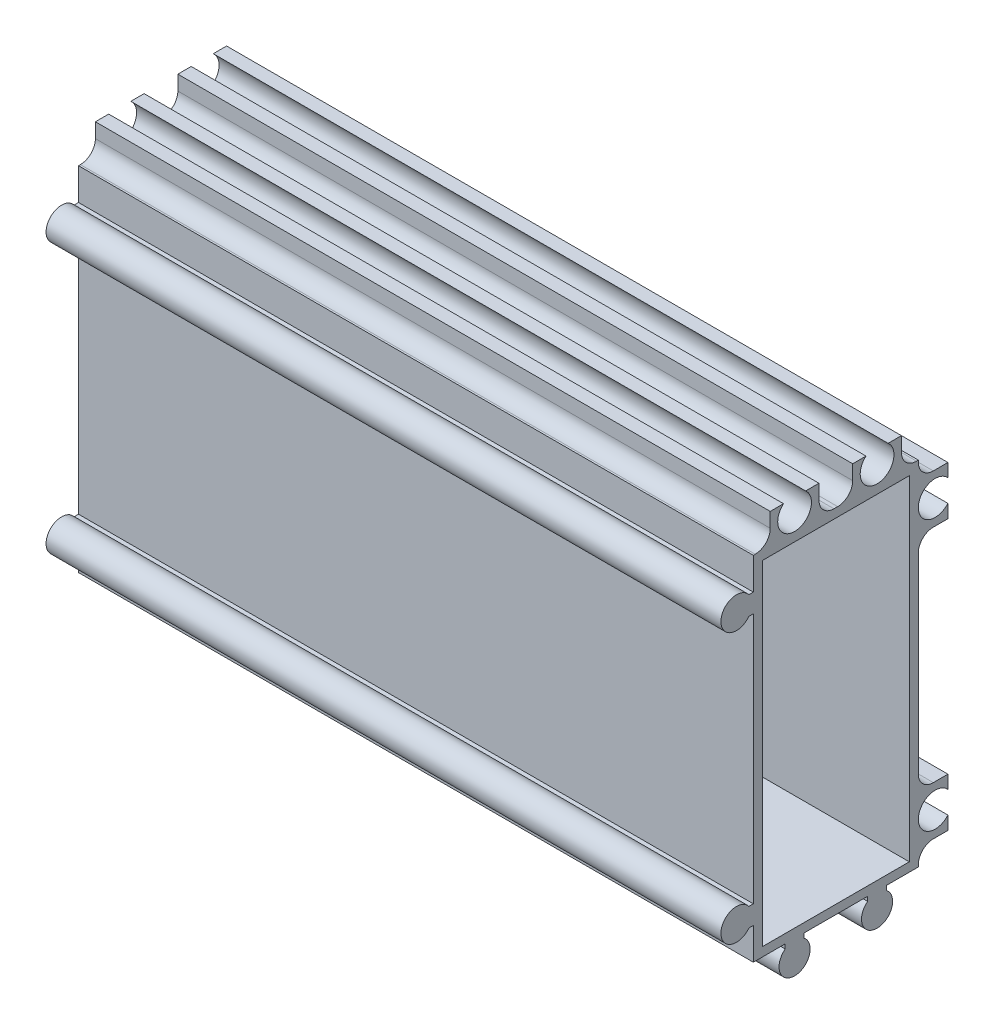
from build123d import *

# Parameters (mm, degrees)
EXTRUDE_1_DEPTH             = 90
SKETCH_2_W                  = 90
SKETCH_2_H                  = 17.75
EXTRUDE_2_DEPTH             = 8.2
SKETCH_3_W                  = 90
SKETCH_3_H                  = 50.95
EXTRUDE_3_DEPTH             = 8.2
SKETCH_4_W                  = 3.95
SKETCH_4_H                  = 29.5
CUT_EXTRUDE_1_DEPTH         = 91
SKETCH_5_W                  = 3.95
SKETCH_5_H                  = 6.2
CUT_EXTRUDE_2_DEPTH         = 91
SKETCH_6_W                  = 2.25
SKETCH_6_H                  = 3.95
CUT_EXTRUDE_3_DEPTH         = 91
SKETCH_7_W                  = 4.5
SKETCH_7_H                  = 3.95
CUT_EXTRUDE_4_DEPTH         = 91
SKETCH_8_W                  = 2.25
SKETCH_8_H                  = 3.95
CUT_EXTRUDE_5_DEPTH         = 91
SKETCH_9_W                  = 3.95
SKETCH_9_H                  = 2.25
CUT_EXTRUDE_6_DEPTH         = 91
SKETCH_10_W                 = 19.6
SKETCH_10_H                 = 44.6
CUT_EXTRUDE_7_DEPTH         = 86.2
HOLE_WIZARD_2_5_2_5_1_D     = 2.5
HOLE_WIZARD_2_5_2_5_1_DEPTH = 90
HOLE_WIZARD_4_5_4_5_1_D     = 4.5
HOLE_WIZARD_4_5_4_5_1_DEPTH = 90
FILLET_1_R                  = 2
FILLET_2_R                  = 2
SKETCH_17_R                 = 1.25
EXTRUDE_4_DEPTH             = 90


with BuildPart() as part:
    # Эскиз1 → Бобышка-Вытянуть1 (new body)
    with BuildSketch(Plane(origin=(90, 0, 0), x_dir=(0, 0, -1), z_dir=(1, 0, 0))):
        with BuildLine():
            Line((6.75, -24.093761792), (6.75, 19.25))
            Line((6.75, 19.25), (-11.593761792, 19.25))
            ThreePointArc((-11.593761792, 19.25), (-15.325, 18), (-11.593761792, 16.75))
            Line((-11.593761792, 16.75), (-11, 16.75))
            Line((-11, 16.75), (-11, -16.75))
            Line((-11, -16.75), (-11.593761792, -16.75))
            ThreePointArc((-11.593761792, -16.75), (-15.325, -18), (-11.593761792, -19.25))
            Line((-11.593761792, -19.25), (-11, -19.25))
            Line((-11, -19.25), (-11, -23.5))
            Line((-11, -23.5), (-6.75, -23.5))
            Line((-6.75, -23.5), (-6.75, -24.093761792))
            ThreePointArc((-6.75, -24.093761792), (-5.5, -27.825), (-4.25, -24.093761792))
            Line((-4.25, -24.093761792), (-4.25, -23.5))
            Line((-4.25, -23.5), (4.25, -23.5))
            Line((4.25, -23.5), (4.25, -24.093761792))
            ThreePointArc((4.25, -24.093761792), (5.5, -27.825), (6.75, -24.093761792))
        make_face()
    extrude(amount=-EXTRUDE_1_DEPTH)

    # Эскиз2 → Бобышка-Вытянуть2 (add)
    with BuildSketch(Plane(origin=(0, 19.25, 0), x_dir=(-1, 0, 0), z_dir=(0, 1, 0))):
        with Locations((-45, 2.125)):
            Rectangle(SKETCH_2_W, SKETCH_2_H)
    extrude(amount=EXTRUDE_2_DEPTH)

    # Эскиз3 → Бобышка-Вытянуть3 (add)
    with BuildSketch(Plane(origin=(0, 0, -6.75), x_dir=(-1, 0, 0), z_dir=(0, 0, -1))):
        with Locations((-45, 1.975)):
            Rectangle(SKETCH_3_W, SKETCH_3_H)
    extrude(amount=EXTRUDE_3_DEPTH)

    # Эскиз4 → Вырез-Вытянуть1 (cut, through all)
    with BuildSketch(Plane.ZY):
        with Locations((-12.975, 0)):
            Rectangle(SKETCH_4_W, SKETCH_4_H)
    extrude(amount=-CUT_EXTRUDE_1_DEPTH, mode=Mode.SUBTRACT)

    # Эскиз5 → Вырез-Вытянуть2 (cut, through all)
    with BuildSketch(Plane.ZY):
        with Locations((-12.975, 24.35)):
            Rectangle(SKETCH_5_W, SKETCH_5_H)
    extrude(amount=-CUT_EXTRUDE_2_DEPTH, mode=Mode.SUBTRACT)

    # Эскиз6 → Вырез-Вытянуть3 (cut, through all)
    with BuildSketch(Plane.ZY):
        with Locations((-9.875, 25.475)):
            Rectangle(SKETCH_6_W, SKETCH_6_H)
    extrude(amount=-CUT_EXTRUDE_3_DEPTH, mode=Mode.SUBTRACT)

    # Эскиз7 → Вырез-Вытянуть4 (cut, through all)
    with BuildSketch(Plane.ZY):
        with Locations((0, 25.475)):
            Rectangle(SKETCH_7_W, SKETCH_7_H)
    extrude(amount=-CUT_EXTRUDE_4_DEPTH, mode=Mode.SUBTRACT)

    # Эскиз8 → Вырез-Вытянуть5 (cut, through all)
    with BuildSketch(Plane.ZY):
        with Locations((9.875, 25.475)):
            Rectangle(SKETCH_8_W, SKETCH_8_H)
    extrude(amount=-CUT_EXTRUDE_5_DEPTH, mode=Mode.SUBTRACT)

    # Эскиз9 → Вырез-Вытянуть6 (cut, through all)
    with BuildSketch(Plane.ZY):
        with Locations((-12.975, -22.375)):
            Rectangle(SKETCH_9_W, SKETCH_9_H)
    extrude(amount=-CUT_EXTRUDE_6_DEPTH, mode=Mode.SUBTRACT)

    # Эскиз10 → Вырез-Вытянуть7 (cut)
    with BuildSketch(Plane(origin=(90, 0, 0), x_dir=(0, 0, -1), z_dir=(1, 0, 0))):
        Rectangle(SKETCH_10_W, SKETCH_10_H)
    extrude(amount=-CUT_EXTRUDE_7_DEPTH, mode=Mode.SUBTRACT)

    # Диаметр отверстия Ø2.5 (2.5)1
    with Locations(Plane(origin=(90, 0, 0), x_dir=(0, 0, -1), z_dir=(1, 0, 0))):
        with Locations((5.5, -25.75), (-13.25, -18), (-5.5, -25.75), (-13.25, 18)):
            Hole(HOLE_WIZARD_2_5_2_5_1_D / 2, depth=HOLE_WIZARD_2_5_2_5_1_DEPTH)

    # Диаметр отверстия Ø4.5 (4.5)1
    with Locations(Plane.ZY):
        with Locations((-13.25, -18), (-13.25, 18), (-5.5, 25.75), (5.5, 25.75)):
            Hole(HOLE_WIZARD_4_5_4_5_1_D / 2, depth=HOLE_WIZARD_4_5_4_5_1_DEPTH)

    # Скругление1
    fillet_1_edges = [part.edges().sort_by_distance(p)[0] for p in [
        (45, 23.5, 8.75),
    ]]
    fillet(fillet_1_edges, radius=FILLET_1_R)

    # Скругление2
    fillet_2_edges = [part.edges().sort_by_distance(p)[0] for p in [
        (45, 23.5, -8.75),
        (45, 23.5, 2.25),
        (45, 23.5, -2.25),
        (45, -21.25, -11),
        (45, 14.75, -11),
        (45, -14.75, -11),
        (45, 21.25, -11),
    ]]
    fillet(fillet_2_edges, radius=FILLET_2_R)

    # Эскиз17 → Бобышка-Вытянуть4 (add)
    with BuildSketch(Plane(origin=(90, 0, 0), x_dir=(0, 0, -1), z_dir=(1, 0, 0))):
        with Locations((5.5, -25.75)):
            Circle(SKETCH_17_R)
        with Locations((-5.5, -25.75)):
            Circle(SKETCH_17_R)
        with Locations((-13.25, -18)):
            Circle(SKETCH_17_R)
        with Locations((-13.25, 18)):
            Circle(SKETCH_17_R)
    extrude(amount=-EXTRUDE_4_DEPTH)


solid = part.part
